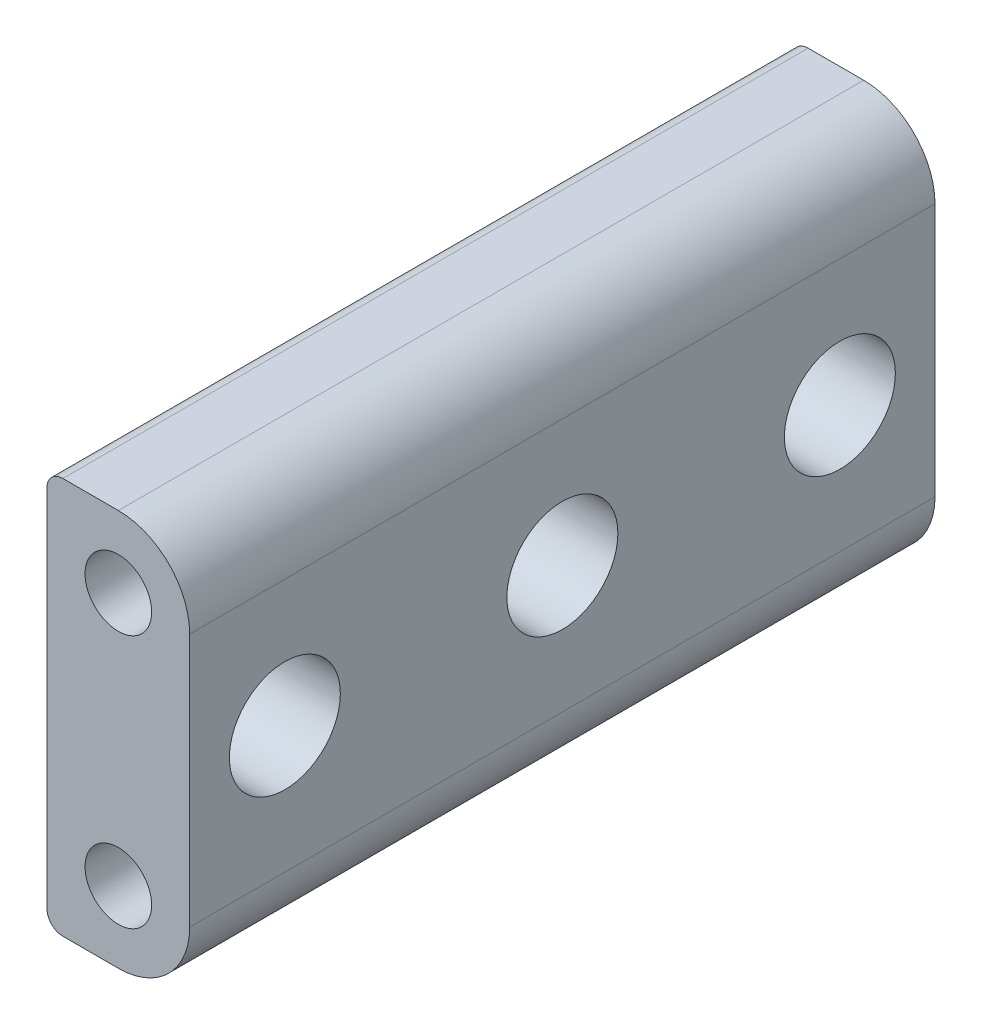
from build123d import *

# Parameters (mm, degrees)
BOSS_EXTRUDE1_DEPTH = 47
SKETCH2_R           = 2.1
CUT_EXTRUDE1_DEPTH  = 4
SKETCH3_R           = 2.1
CUT_EXTRUDE2_DEPTH  = 4
SKETCH4_R           = 3.5
CUT_EXTRUDE3_DEPTH  = 5
FILLET1_R           = 1


with BuildPart() as part:
    # Sketch1 → Boss-Extrude1 (new body)
    with BuildSketch(Plane.XY):
        with BuildLine():
            Line((-4.5, -4.5), (-4.5, 20.5))
            Line((-4.5, 20.5), (0, 20.5))
            ThreePointArc((0, 20.5), (3.181980515, 19.181980515), (4.5, 16))
            Line((4.5, 16), (4.5, 0))
            ThreePointArc((4.5, 0), (3.181980515, -3.181980515), (0, -4.5))
            Line((0, -4.5), (-4.5, -4.5))
        make_face()
    extrude(amount=BOSS_EXTRUDE1_DEPTH)

    # Sketch2 → Cut-Extrude1 (cut)
    with BuildSketch(Plane.XY.offset(47)):
        with Locations((0, 16)):
            Circle(SKETCH2_R)
        Circle(SKETCH2_R)
    extrude(amount=-CUT_EXTRUDE1_DEPTH, mode=Mode.SUBTRACT)

    # Sketch3 → Cut-Extrude2 (cut)
    with BuildSketch(Plane(origin=(0, 0, 0), x_dir=(-1, 0, 0), z_dir=(0, 0, -1))):
        Circle(SKETCH3_R)
        with Locations((0, 16)):
            Circle(SKETCH3_R)
    extrude(amount=-CUT_EXTRUDE2_DEPTH, mode=Mode.SUBTRACT)

    # Sketch4 → Cut-Extrude3 (cut)
    with BuildSketch(Plane(origin=(4.5, 0, 0), x_dir=(0, 0, -1), z_dir=(1, 0, 0))):
        with Locations((-41, 8)):
            Circle(SKETCH4_R)
        with Locations((-23.5, 8)):
            Circle(SKETCH4_R)
        with Locations((-6, 8)):
            Circle(SKETCH4_R)
    extrude(amount=-CUT_EXTRUDE3_DEPTH, mode=Mode.SUBTRACT)

    # Fillet1
    fillet1_edges = [part.edges().sort_by_distance(p)[0] for p in [
        (-4.5, -4.5, 23.5),
        (-4.5, 20.5, 23.5),
    ]]
    fillet(fillet1_edges, radius=FILLET1_R)


solid = part.part
